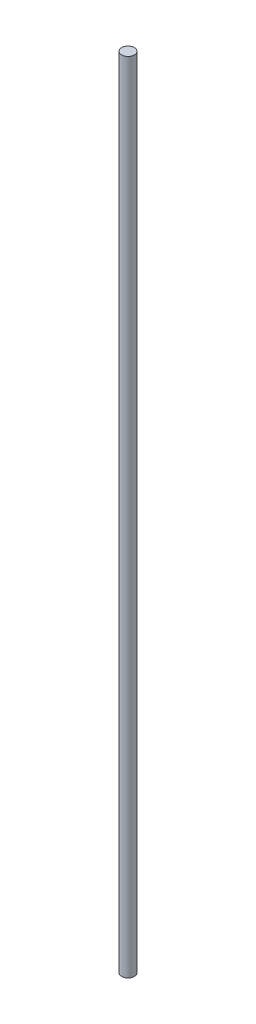
from build123d import *

# Parameters (mm, degrees)
SKETCH1_R           = 0.5
BOSS_EXTRUDE1_DEPTH = 62.5


with BuildPart() as part:
    # Sketch1 → Boss-Extrude1 (new body)
    with BuildSketch(Plane(origin=(0, 0, 0), x_dir=(1, 0, 0), z_dir=(0, 1, 0))):
        Circle(SKETCH1_R)
    extrude(amount=BOSS_EXTRUDE1_DEPTH)


solid = part.part
